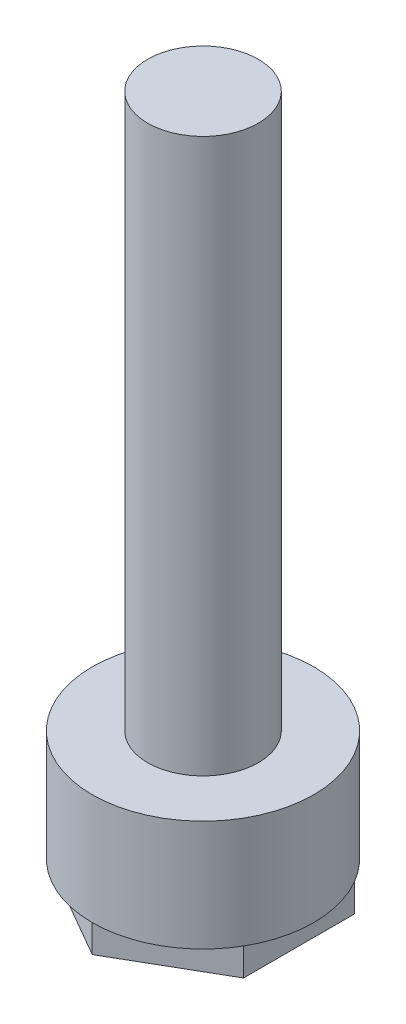
from build123d import *

# Parameters (mm, degrees)
SKETCH1_R           = 2
BOSS_EXTRUDE1_DEPTH = 2.5
SKETCH2_R           = 1
BOSS_EXTRUDE2_DEPTH = 10
CUT_EXTRUDE3_DEPTH  = 0.5


with BuildPart() as part:
    # Sketch1 → Boss-Extrude1 (new body)
    with BuildSketch(Plane(origin=(0, 0, 0), x_dir=(1, 0, 0), z_dir=(0, 1, 0))):
        Circle(SKETCH1_R)
    extrude(amount=BOSS_EXTRUDE1_DEPTH)

    # Sketch2 → Boss-Extrude2 (add)
    with BuildSketch(Plane(origin=(0, 2.5, 0), x_dir=(1, 0, 0), z_dir=(0, 1, 0))):
        Circle(SKETCH2_R)
    extrude(amount=BOSS_EXTRUDE2_DEPTH)

    # Sketch3 → Cut-Extrude3 (cut)
    with BuildSketch(Plane.XZ):
        with BuildLine():
            Line((-1.732050808, 1), (0, 2))
            ThreePointArc((0, 2), (-1, 1.732050808), (-1.732050808, 1))
        make_face()
        with BuildLine():
            Line((-1.732050808, -1), (-1.732050808, 1))
            ThreePointArc((-1.732050808, 1), (-2, 0), (-1.732050808, -1))
        make_face()
        with BuildLine():
            Line((0, -2), (-1.732050808, -1))
            ThreePointArc((-1.732050808, -1), (-1, -1.732050808), (0, -2))
        make_face()
        with BuildLine():
            ThreePointArc((0, -2), (1, -1.732050808), (1.732050808, -1))
            Line((1.732050808, -1), (0, -2))
        make_face()
        with BuildLine():
            ThreePointArc((2, 0), (1.931851653, 0.51763809), (1.732050808, 1))
            Line((1.732050808, 1), (1.732050808, -1))
            ThreePointArc((1.732050808, -1), (1.931851653, -0.51763809), (2, 0))
        make_face()
        with BuildLine():
            ThreePointArc((1.732050808, 1), (1, 1.732050808), (0, 2))
            Line((0, 2), (1.732050808, 1))
        make_face()
    extrude(amount=-CUT_EXTRUDE3_DEPTH, mode=Mode.SUBTRACT)


solid = part.part
